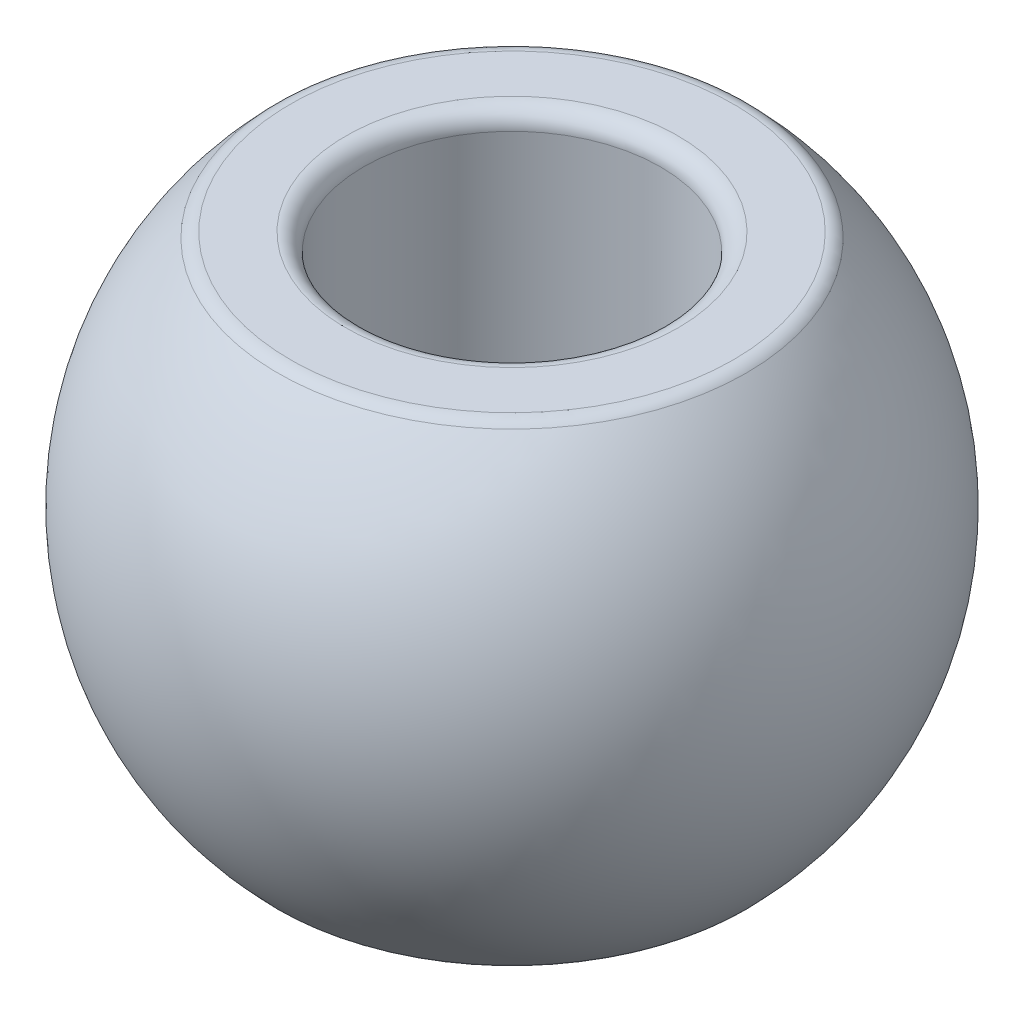
from build123d import *

# Parameters (mm, degrees)
FILLET1_R = 0.3


with BuildPart() as part:
    # Sketch1 → Revolve1 (revolve)
    with BuildSketch(Plane.XY):
        with BuildLine():
            Line((3.854610875, 4), (2.5, 4))
            Line((2.5, 4), (2.5, -4))
            Line((2.5, -4), (3.854610875, -4))
            ThreePointArc((3.854610875, -4), (5.555, 0), (3.854610875, 4))
        make_face()
    revolve(axis=Axis((0, 4, 0), (0, -1, 0)))

    # Fillet1
    fillet1_edges = [part.edges().sort_by_distance(p)[0] for p in [
        (-3.854610875, -4, 0),
        (-2.5, -4, 0),
        (-2.5, 4, 0),
        (-3.854610875, 4, 0),
    ]]
    fillet(fillet1_edges, radius=FILLET1_R)


solid = part.part
